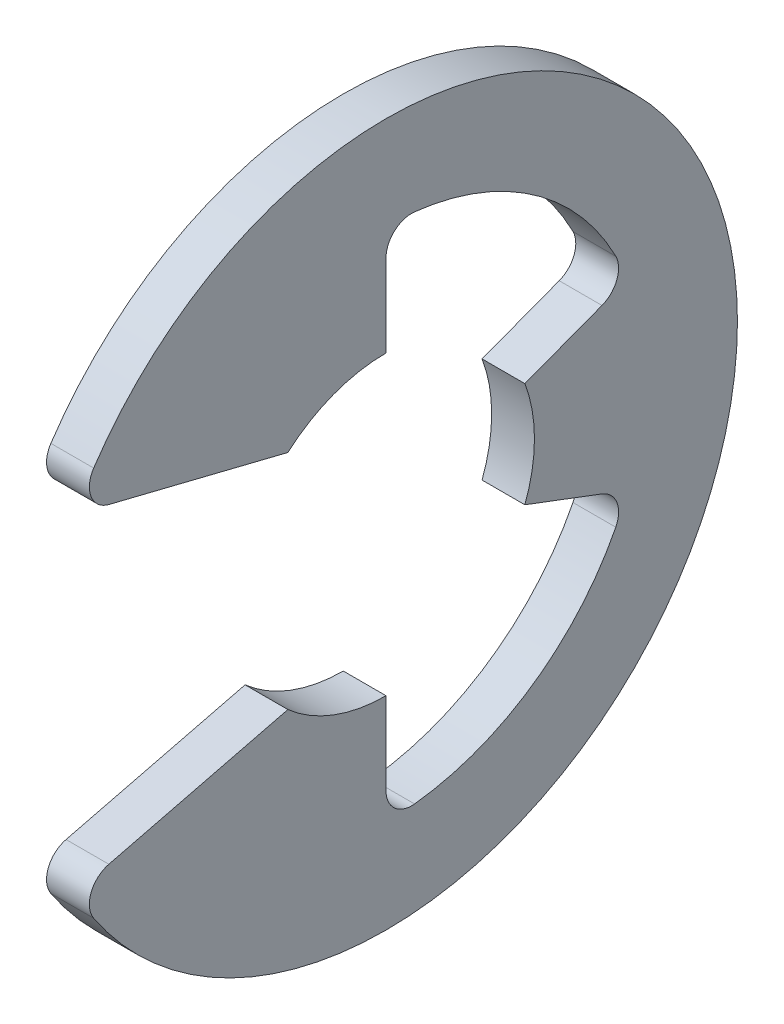
from build123d import *

# Parameters (mm, degrees)
EXTRUDE1_DEPTH = 0.6
FILLET1_R      = 0.72


with BuildPart() as part:
    # Sketch1 → Extrude1 (new body, symmetric)
    with BuildSketch(Plane(origin=(0, 0, 0), x_dir=(0, 0, -1), z_dir=(1, 0, 0))):
        with BuildLine():
            Line((-8.710253959, -4.599345167), (-2.751581364, -3.12))
            ThreePointArc((-2.751581364, -3.12), (-1.470782105, -3.891323682), (0, -4.16))
            Line((0, -4.16), (0, -7.230967742))
            ThreePointArc((0, -7.230967742), (4.111002655, -5.948659652), (6.763950966, -2.556533162))
            Line((6.763950966, -2.556533162), (3.891323682, -1.470782105))
            ThreePointArc((3.891323682, -1.470782105), (4.16, 0), (3.891323682, 1.470782105))
            Line((3.891323682, 1.470782105), (6.763950966, 2.556533162))
            ThreePointArc((6.763950966, 2.556533162), (4.111002655, 5.948659652), (0, 7.230967742))
            Line((0, 7.230967742), (0, 4.16))
            ThreePointArc((0, 4.16), (-1.470782105, 3.891323682), (-2.751581364, 3.12))
            Line((-2.751581364, 3.12), (-8.710253959, 4.599345167))
            ThreePointArc((-8.710253959, 4.599345167), (9.85, 0), (-8.710253959, -4.599345167))
        make_face()
    extrude(amount=EXTRUDE1_DEPTH, both=True)

    # Fillet1
    fillet1_edges = [part.edges().sort_by_distance(p)[0] for p in [
        (0, -4.599345167, 8.710253959),
        (0, -7.230967742, 0),
        (0, -2.556533162, -6.763950966),
        (0, 2.556533162, -6.763950966),
        (0, 7.230967742, 0),
        (0, 4.599345167, 8.710253959),
    ]]
    fillet(fillet1_edges, radius=FILLET1_R)


solid = part.part
